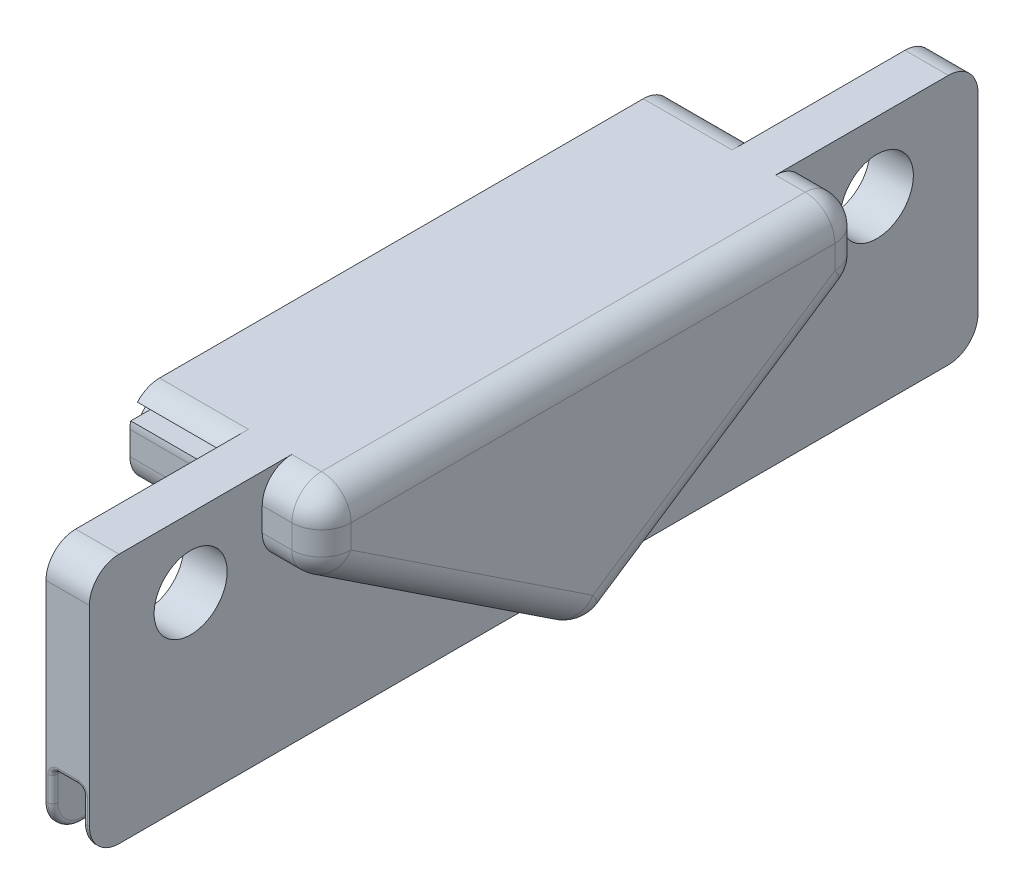
from build123d import *

# Parameters (mm, degrees)
BOSS_EXTRUDE1_DEPTH     = 12.7
SKETCH7_W               = 13.75
SKETCH7_H               = 0.65
CUT_EXTRUDE2_DEPTH      = 4
SKETCH7_4_R             = 1.6
BOSS_EXTRUDE2_DEPTH     = 1.4
CUT_EXTRUDE3_DEPTH      = 4.5
SKETCH7_6_R             = 1.85
CUT_EXTRUDE4_DEPTH      = 2.4
CUT_EXTRUDE4_DEPTH_BACK = 10.7
CUT_EXTRUDE5_DEPTH      = 3
SKETCH12_W              = 1.5
SKETCH12_H              = 22.5
CUT_EXTRUDE6_DEPTH      = 3
SKETCH14_W              = 2.2
SKETCH14_H              = 4
BOSS_EXTRUDE3_DEPTH     = 1
FILLET5_R               = 1.5
FILLET6_R               = 0.25


with BuildPart() as part:
    # Sketch1 → Boss-Extrude1 (new body)
    with BuildSketch(Plane(origin=(0, 0, 0), x_dir=(1, 0, 0), z_dir=(0, 1, 0))):
        Polygon((-28.77817965, 16.29419618), (-24.27817965, 16.29419618), (-24.27817965, 25.04419618), (-22.07817965, 25.04419618), (-22.07817965, 16.29419618), (-19.07817965, 16.29419618), (-19.07817965, 2.54419618), (-28.77817965, 2.54419618), align=None)
    extrude(amount=BOSS_EXTRUDE1_DEPTH)

    # Sketch7 → Cut-Extrude2 (cut)
    with BuildSketch(Plane.ZY.offset(28.77817965)):
        with Locations((-9.41919618, 11.875)):
            Rectangle(SKETCH7_W, SKETCH7_H)
    extrude(amount=-CUT_EXTRUDE2_DEPTH, mode=Mode.SUBTRACT)

    # Sketch7_4 → Boss-Extrude2 (add)
    with BuildSketch(Plane.ZY.offset(28.77817965)):
        with Locations((-13.04419618, 9.2)):
            Circle(SKETCH7_4_R)
    extrude(amount=BOSS_EXTRUDE2_DEPTH)

    # Sketch7_5 → Cut-Extrude3 (cut)
    with BuildSketch(Plane.ZY.offset(28.77817965)):
        Polygon((-2.54419618, 0.097302003), (-16.29419618, 9.2), (-16.29419618, 0), (-2.54419618, 0), align=None)
    extrude(amount=-CUT_EXTRUDE3_DEPTH, mode=Mode.SUBTRACT)

    # Sketch7_6 → Cut-Extrude4 (cut, two sides)
    with BuildSketch(Plane.ZY.offset(28.77817965)) as cut_extrude4_sk:
        with Locations((-19.91919618, 9.2)):
            Circle(SKETCH7_6_R)
    extrude(amount=CUT_EXTRUDE4_DEPTH, mode=Mode.SUBTRACT)
    extrude(cut_extrude4_sk.sketch, amount=-CUT_EXTRUDE4_DEPTH_BACK, mode=Mode.SUBTRACT)

    # Sketch10 → Cut-Extrude5 (cut)
    with BuildSketch(Plane(origin=(-22.07817965, 0, 0), x_dir=(0, 0, -1), z_dir=(1, 0, 0))):
        Polygon((16.29419618, 9.2), (16.29419618, 0), (2.54419618, 0), (2.54419618, 0.097302003), align=None)
    extrude(amount=CUT_EXTRUDE5_DEPTH, mode=Mode.SUBTRACT)

    # Sketch12 → Cut-Extrude6 (cut)
    with BuildSketch(Plane.XZ):
        with Locations((-23.17817965, -13.79419618)):
            Rectangle(SKETCH12_W, SKETCH12_H)
    extrude(amount=-CUT_EXTRUDE6_DEPTH, mode=Mode.SUBTRACT)

    # Sketch14 → Boss-Extrude3 (add)
    with BuildSketch(Plane(origin=(0, 0, 0), x_dir=(-1, 0, 0), z_dir=(0, -1, 0))):
        with Locations((23.17817965, 4.54419618)):
            Rectangle(SKETCH14_W, SKETCH14_H)
    extrude(amount=-BOSS_EXTRUDE3_DEPTH)

    # Mirror3: part across plane


with BuildPart() as part_1:
    add(part.part)
    add(part.part.mirror(Plane(origin=(-19.07817965, 12.7, -2.54419618), x_dir=(1, 0, 0), z_dir=(0, 0, -1))))

    # Fillet5
    fillet5_edges = [part_1.edges().sort_by_distance(p)[0] for p in [
        (-19.07817965, 12.7, -2.54419618),
        (-19.07817965, 10.95, -16.29419618),
        (-26.52817965, 12.7, 11.20580382),
        (-19.07817965, 10.95, 11.20580382),
        (-19.07817965, 4.648651002, 4.33080382),
        (-20.57817965, 12.7, 11.20580382),
        (-20.57817965, 9.2, 11.20580382),
        (-23.17817965, 12.7, 19.95580382),
        (-24.10317965, 0, 19.95580382),
        (-22.25317965, 0, 19.95580382),
        (-26.52817965, 9.2, 11.20580382),
        (-20.57817965, 0.097302003, -2.54419618),
        (-20.57817965, 12.7, -16.29419618),
        (-23.17817965, 12.7, -25.04419618),
        (-26.52817965, 12.7, -16.29419618),
        (-26.52817965, 9.2, -16.29419618),
        (-19.07817965, 4.648651002, -9.41919618),
        (-20.57817965, 9.2, -16.29419618),
        (-24.10317965, 0, -25.04419618),
        (-22.25317965, 0, -25.04419618),
    ]]
    fillet(fillet5_edges, radius=FILLET5_R)

    # Fillet6
    fillet6_edges = [part_1.edges().sort_by_distance(p)[0] for p in [
        (-23.92817965, 0, -15.04419618),
        (-23.92817965, 1, -2.54419618),
        (-23.92817965, 0.5, -6.54419618),
        (-23.17817965, 1, -6.54419618),
        (-22.42817965, 0.5, -6.54419618),
        (-22.42817965, 1, -2.54419618),
        (-23.17817965, 0, -6.54419618),
        (-23.17817965, 3, 19.95580382),
        (-22.42817965, 2.25, 19.95580382),
        (-23.92817965, 0, 9.95580382),
        (-23.92817965, 2.25, 19.95580382),
        (-22.42817965, 0.5, 1.45580382),
        (-23.92817965, 0.5, 1.45580382),
        (-23.17817965, 0, 1.45580382),
        (-23.17817965, 1, 1.45580382),
        (-22.42817965, 0, -15.04419618),
        (-22.42817965, 0, 9.95580382),
        (-22.42817965, 0.439339828, -24.604856352),
        (-22.42817965, 0.439339828, 19.516463992),
        (-23.92817965, 0.439339828, -24.604856352),
        (-23.92817965, 0.439339828, 19.516463992),
        (-22.42817965, 3, -2.54419618),
        (-23.17817965, 3, -25.04419618),
        (-22.42817965, 2.25, -25.04419618),
        (-23.92817965, 3, -2.54419618),
        (-23.92817965, 2.25, -25.04419618),
    ]]
    fillet(fillet6_edges, radius=FILLET6_R)


solid = part_1.part
